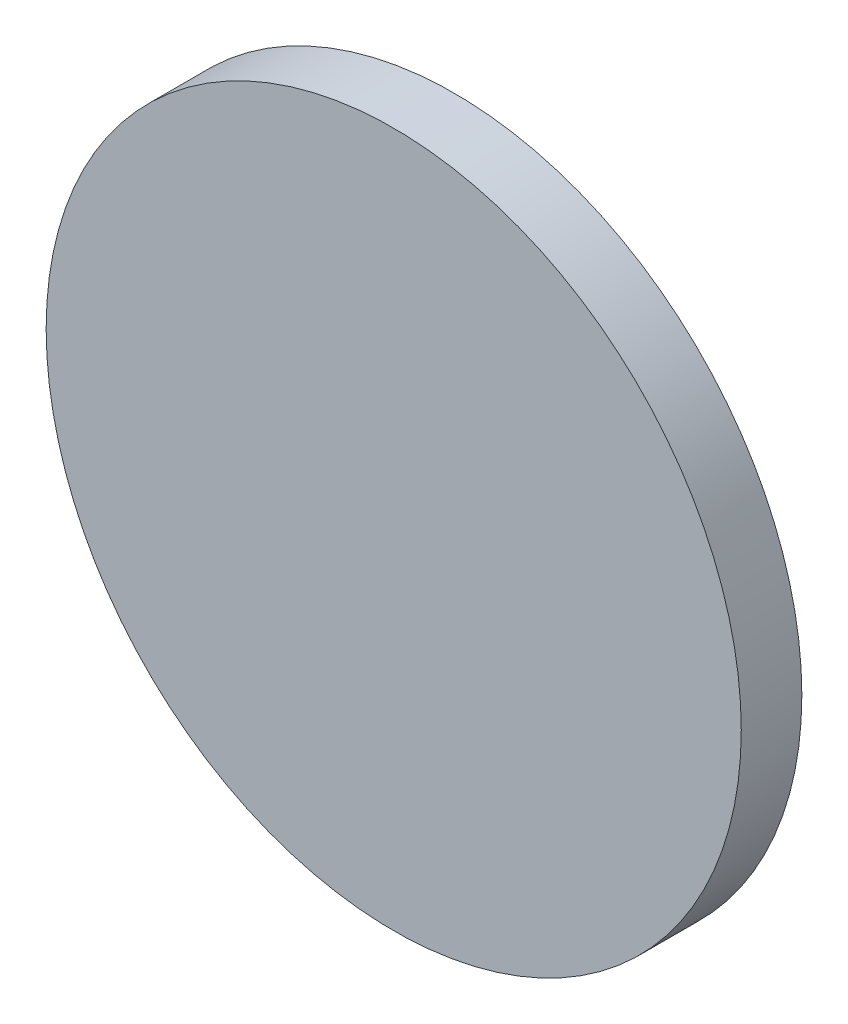
from build123d import *

# Parameters (mm, degrees)
SKETCH1_R           = 57.3785
BOSS_EXTRUDE1_DEPTH = 10


with BuildPart() as part:
    # Sketch1 → Boss-Extrude1 (new body)
    with BuildSketch(Plane.XY):
        Circle(SKETCH1_R)
    extrude(amount=-BOSS_EXTRUDE1_DEPTH)


solid = part.part
